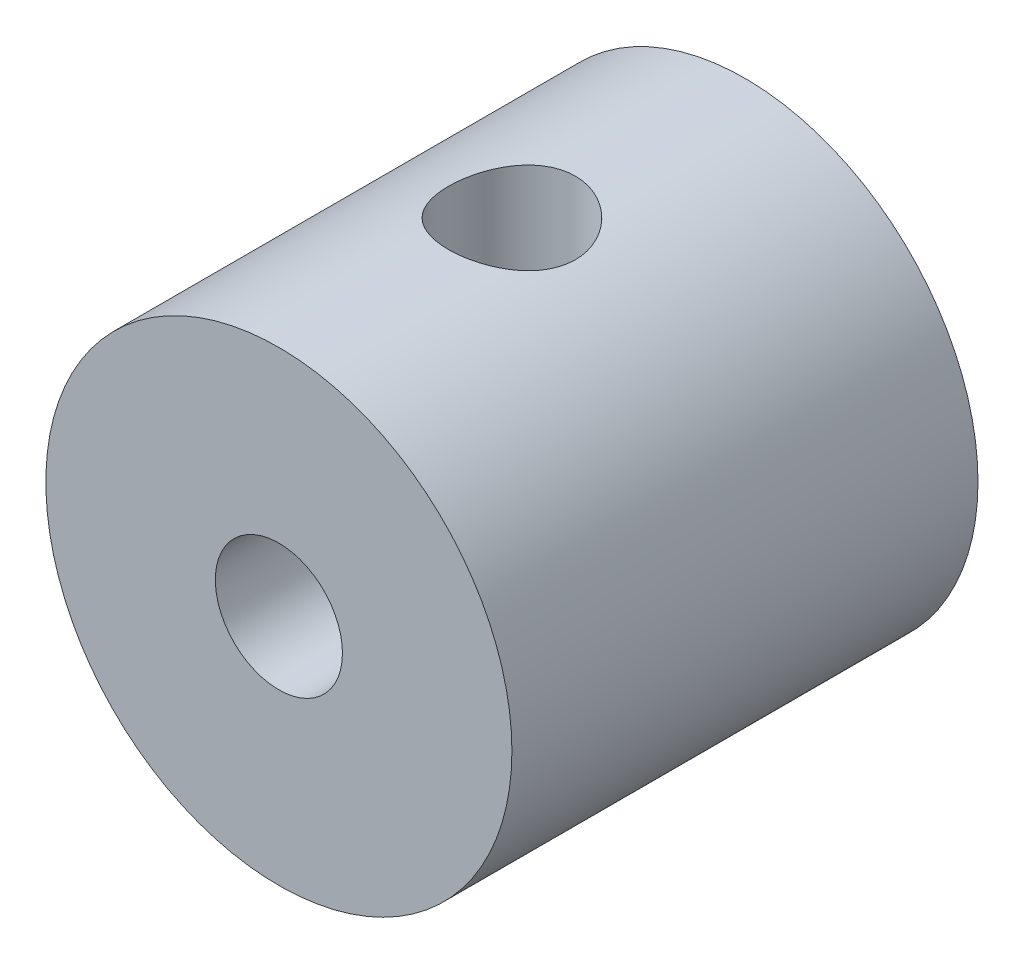
from build123d import *

# Parameters (mm, degrees)
SKETCH_1_R          = 2.75
SKETCH_1_R_2        = 0.75
EXTRUDE_1_DEPTH     = 5.5
SKETCH_2_R          = 0.75
CUT_EXTRUDE_1_DEPTH = 2.75


with BuildPart() as part:
    # 草图1 → 凸台-拉伸1 (new body)
    with BuildSketch(Plane.XY):
        Circle(SKETCH_1_R)
        Circle(SKETCH_1_R_2, mode=Mode.SUBTRACT)
    extrude(amount=EXTRUDE_1_DEPTH)

    # 草图2 → 切除-拉伸1 (cut, symmetric)
    with BuildSketch(Plane(origin=(0, 0, 0), x_dir=(1, 0, 0), z_dir=(0, 1, 0))):
        with Locations((0, -2.75)):
            Circle(SKETCH_2_R)
    extrude(amount=CUT_EXTRUDE_1_DEPTH, both=True, mode=Mode.SUBTRACT)


solid = part.part
